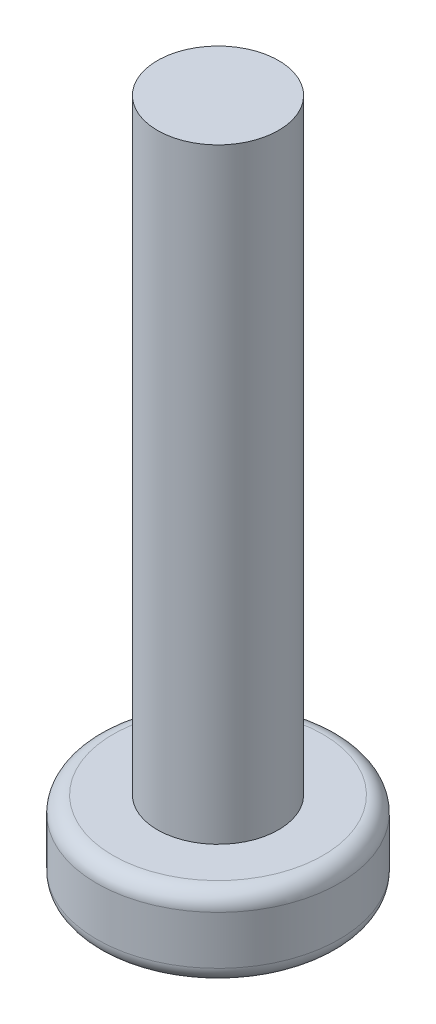
from build123d import *

# Parameters (mm, degrees)
SKETCH1_R           = 3
BOSS_EXTRUDE1_DEPTH = 2
SKETCH2_R           = 1.5
BOSS_EXTRUDE2_DEPTH = 15
SKETCH3_W           = 0.9
SKETCH3_H           = 0.9
SKETCH3_W_2         = 1.05
SKETCH3_H_2         = 1.05
CUT_EXTRUDE1_DEPTH  = 1.9
FILLET1_R           = 0.4


with BuildPart() as part:
    # Sketch1 → Boss-Extrude1 (new body)
    with BuildSketch(Plane(origin=(0, 0, 0), x_dir=(1, 0, 0), z_dir=(0, 1, 0))):
        Circle(SKETCH1_R)
    extrude(amount=BOSS_EXTRUDE1_DEPTH)

    # Sketch2 → Boss-Extrude2 (add)
    with BuildSketch(Plane(origin=(0, 2, 0), x_dir=(1, 0, 0), z_dir=(0, 1, 0))):
        Circle(SKETCH2_R)
    extrude(amount=BOSS_EXTRUDE2_DEPTH)

    # Sketch3 → Cut-Extrude1 (cut)
    with BuildSketch(Plane(origin=(0, 0, 0), x_dir=(-1, 0, 0), z_dir=(0, -1, 0))):
        Rectangle(SKETCH3_W, SKETCH3_H)
        with Locations((0.975, 0)):
            Rectangle(SKETCH3_W_2, SKETCH3_H)
        with Locations((0, -0.975)):
            Rectangle(SKETCH3_W, SKETCH3_H_2)
        with Locations((-0.975, 0)):
            Rectangle(SKETCH3_W_2, SKETCH3_H)
        with Locations((0, 0.975)):
            Rectangle(SKETCH3_W, SKETCH3_H_2)
    extrude(amount=-CUT_EXTRUDE1_DEPTH, mode=Mode.SUBTRACT)

    # Fillet1
    fillet1_edges = [part.edges().sort_by_distance(p)[0] for p in [
        (-3, 0, 0),
        (-3, 2, 0),
    ]]
    fillet(fillet1_edges, radius=FILLET1_R)


solid = part.part
